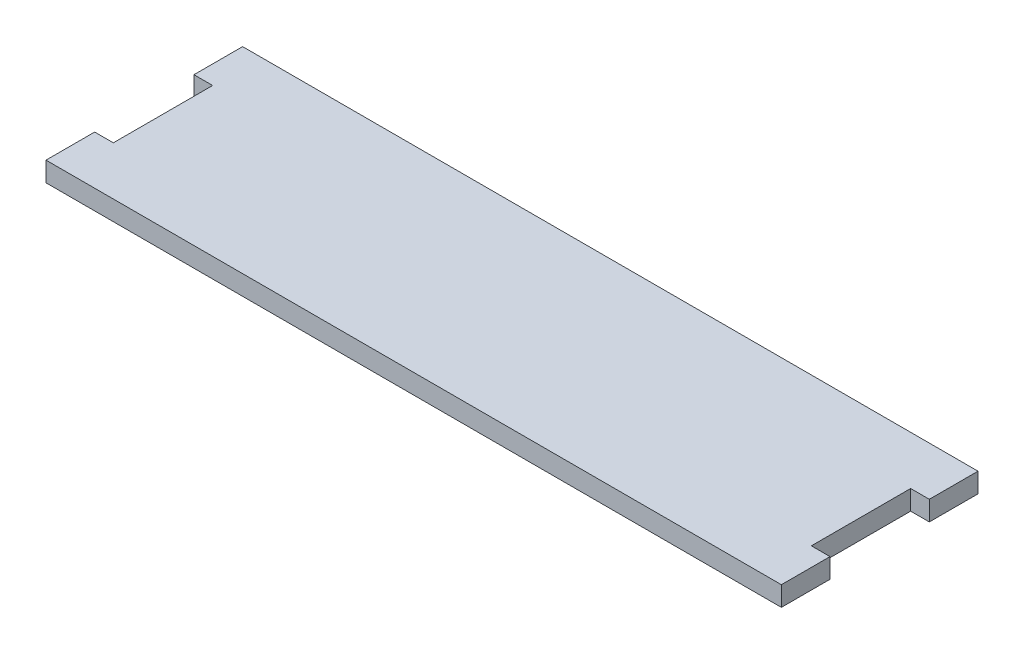
from build123d import *

# Parameters (mm, degrees)
BOSS_EXTRUDE1_DEPTH = 5.08


with BuildPart() as part:
    # Sketch1 → Boss-Extrude1 (new body)
    with BuildSketch(Plane(origin=(0, 0, 0), x_dir=(1, 0, 0), z_dir=(0, 1, 0))):
        Polygon((-90.17, -25.4), (90.17, -25.4), (94.996, -25.4), (94.996, -12.827), (90.17, -12.827), (90.17, 12.827), (94.996, 12.827), (94.996, 25.4), (90.17, 25.4), (-90.17, 25.4), (-94.996, 25.4), (-94.996, 12.827), (-90.17, 12.827), (-90.17, -12.827), (-94.996, -12.827), (-94.996, -25.4), align=None)
    extrude(amount=BOSS_EXTRUDE1_DEPTH)


solid = part.part
